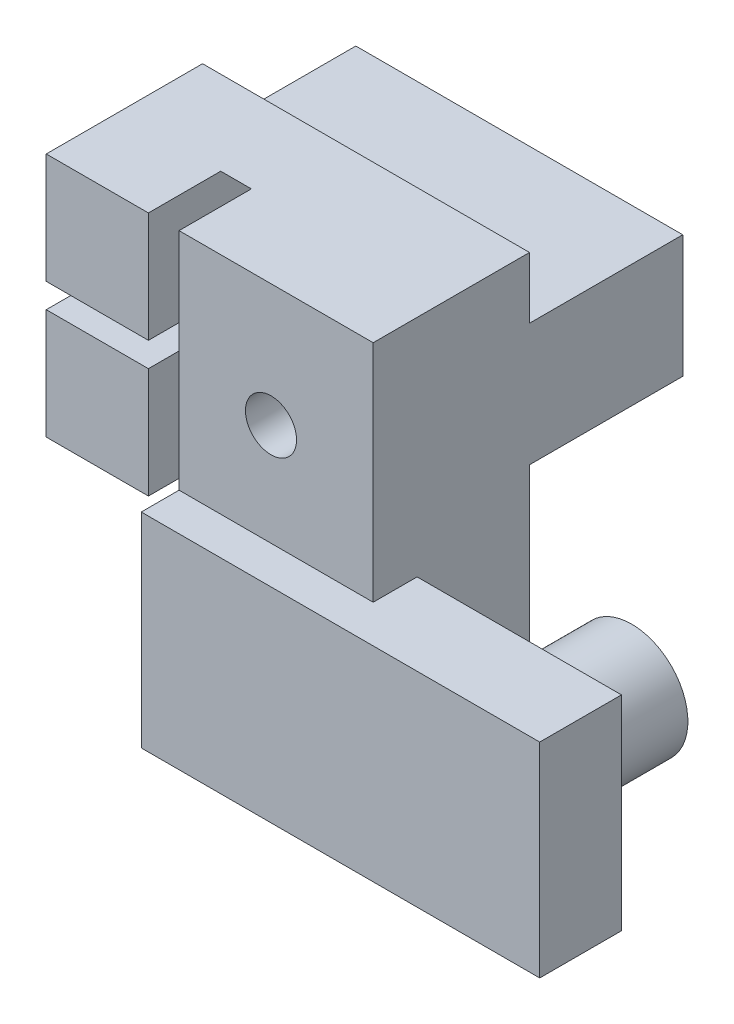
from build123d import *

# Parameters (mm, degrees)
SKETCH_1_W          = 16
SKETCH_1_H          = 12
EXTRUDE_1_DEPTH     = 7.65
SKETCH_2_W          = 5
SKETCH_2_H          = 1.2
CUT_EXTRUDE_1_DEPTH = 4.5
SKETCH_3_R          = 7.15
CUT_EXTRUDE_2_DEPTH = 1.5
SKETCH_4_W          = 16
SKETCH_4_H          = 6
EXTRUDE_2_DEPTH     = 7.5
SKETCH_5_R          = 2.25
CUT_EXTRUDE_3_DEPTH = 7.5
SKETCH_6_R          = 1.25
CUT_EXTRUDE_4_DEPTH = 8.65
SKETCH_7_W          = 9.5
SKETCH_7_H          = 7.65
EXTRUDE_3_DEPTH     = 9
EXTRUDE_START       = -9.5
SKETCH_8_W          = 4
SKETCH_8_H          = 10
EXTRUDE_4_DEPTH     = 19.5
SKETCH_9_R          = 2.75
EXTRUDE_5_DEPTH     = 5.5


with BuildPart() as part:
    # Эскиз1 → Бобышка-Вытянуть1 (new body)
    with BuildSketch(Plane.XY):
        with Locations((-13.599693696, 25)):
            Rectangle(SKETCH_1_W, SKETCH_1_H)
    extrude(amount=EXTRUDE_1_DEPTH)

    # Эскиз2 → Вырез-Вытянуть1 (cut)
    with BuildSketch(Plane.XY.offset(7.65)):
        with Locations((-19.099693696, 25)):
            Rectangle(SKETCH_2_W, SKETCH_2_H)
    extrude(amount=-CUT_EXTRUDE_1_DEPTH, mode=Mode.SUBTRACT)

    # Эскиз3 → Вырез-Вытянуть2 (cut)
    with BuildSketch(Plane.ZY.offset(16.599693696)):
        with Locations((8, 25)):
            Circle(SKETCH_3_R)
    extrude(amount=-CUT_EXTRUDE_2_DEPTH, mode=Mode.SUBTRACT)

    # Эскиз4 → Бобышка-Вытянуть2 (add)
    with BuildSketch(Plane(origin=(0, 0, 0), x_dir=(-1, 0, 0), z_dir=(0, 0, -1))):
        with Locations((13.599693696, 25)):
            Rectangle(SKETCH_4_W, SKETCH_4_H)
    extrude(amount=EXTRUDE_2_DEPTH)

    # Эскиз5 → Вырез-Вытянуть3 (cut)
    with BuildSketch(Plane(origin=(0, 0, -7.5), x_dir=(-1, 0, 0), z_dir=(0, 0, -1))):
        with Locations((10.599693696, 25)):
            Circle(SKETCH_5_R)
    extrude(amount=-CUT_EXTRUDE_3_DEPTH, mode=Mode.SUBTRACT)

    # Эскиз6 → Вырез-Вытянуть4 (cut, through all)
    with BuildSketch(Plane(origin=(0, 0, 0), x_dir=(-1, 0, 0), z_dir=(0, 0, -1))):
        with Locations((10.599693696, 25)):
            Circle(SKETCH_6_R)
    extrude(amount=-CUT_EXTRUDE_4_DEPTH, mode=Mode.SUBTRACT)

    # Эскиз7 → Бобышка-Вытянуть3 (add)
    with BuildSketch(Plane.XZ.offset(-19)):
        with Locations((-10.349693696, 3.825)):
            Rectangle(SKETCH_7_W, SKETCH_7_H)
    extrude(amount=EXTRUDE_3_DEPTH)

    # Эскиз8 → Бобышка-Вытянуть4 (add)
    with BuildSketch(Plane(origin=(-5.599693696, 0, 0), x_dir=(0, 0, -1), z_dir=(1, 0, 0)).offset(EXTRUDE_START)):
        with Locations((-7.5, 15)):
            Rectangle(SKETCH_8_W, SKETCH_8_H)
    extrude(amount=EXTRUDE_4_DEPTH)

    # Эскиз9 → Бобышка-Вытянуть5 (add)
    with BuildSketch(Plane(origin=(0, 0, 5.5), x_dir=(-1, 0, 0), z_dir=(0, 0, -1))):
        with Locations((0.599693696, 15)):
            Circle(SKETCH_9_R)
    extrude(amount=EXTRUDE_5_DEPTH)


solid = part.part
